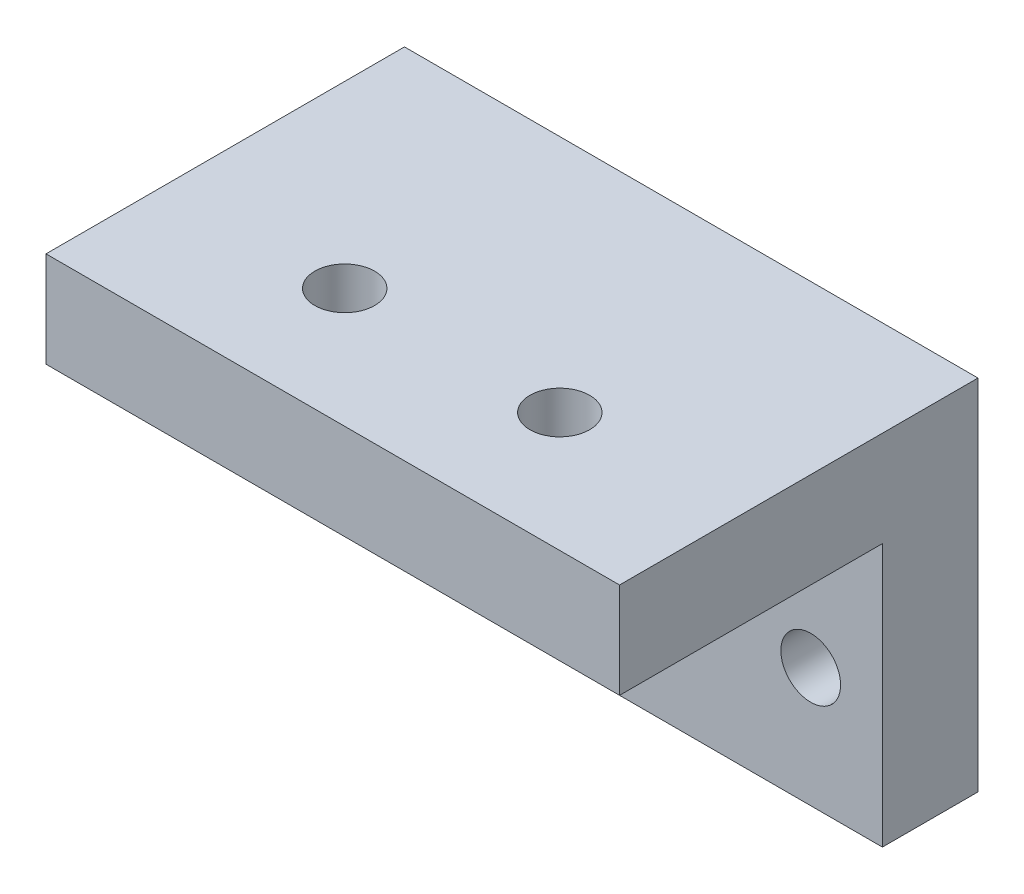
from build123d import *

# Parameters (mm, degrees)
SKETCH_1_W          = 24
SKETCH_1_H          = 15
EXTRUDE_1_DEPTH     = 4
SKETCH_2_W          = 24
SKETCH_2_H          = 4
EXTRUDE_2_DEPTH     = 11
SKETCH_3_R          = 1.25
CUT_EXTRUDE_1_DEPTH = 5
SKETCH_4_R          = 1.25
CUT_EXTRUDE_2_DEPTH = 5


with BuildPart() as part:
    # 草图1 → 凸台-拉伸1 (new body)
    with BuildSketch(Plane.XY):
        Rectangle(SKETCH_1_W, SKETCH_1_H)
    extrude(amount=EXTRUDE_1_DEPTH)

    # 草图2 → 凸台-拉伸2 (add)
    with BuildSketch(Plane.XY.offset(4)):
        with Locations((0, 5.5)):
            Rectangle(SKETCH_2_W, SKETCH_2_H)
    extrude(amount=EXTRUDE_2_DEPTH)

    # 草图3 → 切除-拉伸1 (cut, through all)
    with BuildSketch(Plane.XY.offset(4)):
        with Locations((-9, -2.5)):
            Circle(SKETCH_3_R)
        with Locations((9, -2.5)):
            Circle(SKETCH_3_R)
    extrude(amount=-CUT_EXTRUDE_1_DEPTH, mode=Mode.SUBTRACT)

    # 草图4 → 切除-拉伸2 (cut, through all)
    with BuildSketch(Plane.XZ.offset(-3.5)):
        with Locations((-4.5, 10)):
            Circle(SKETCH_4_R)
        with Locations((4.5, 10)):
            Circle(SKETCH_4_R)
    extrude(amount=-CUT_EXTRUDE_2_DEPTH, mode=Mode.SUBTRACT)


solid = part.part
